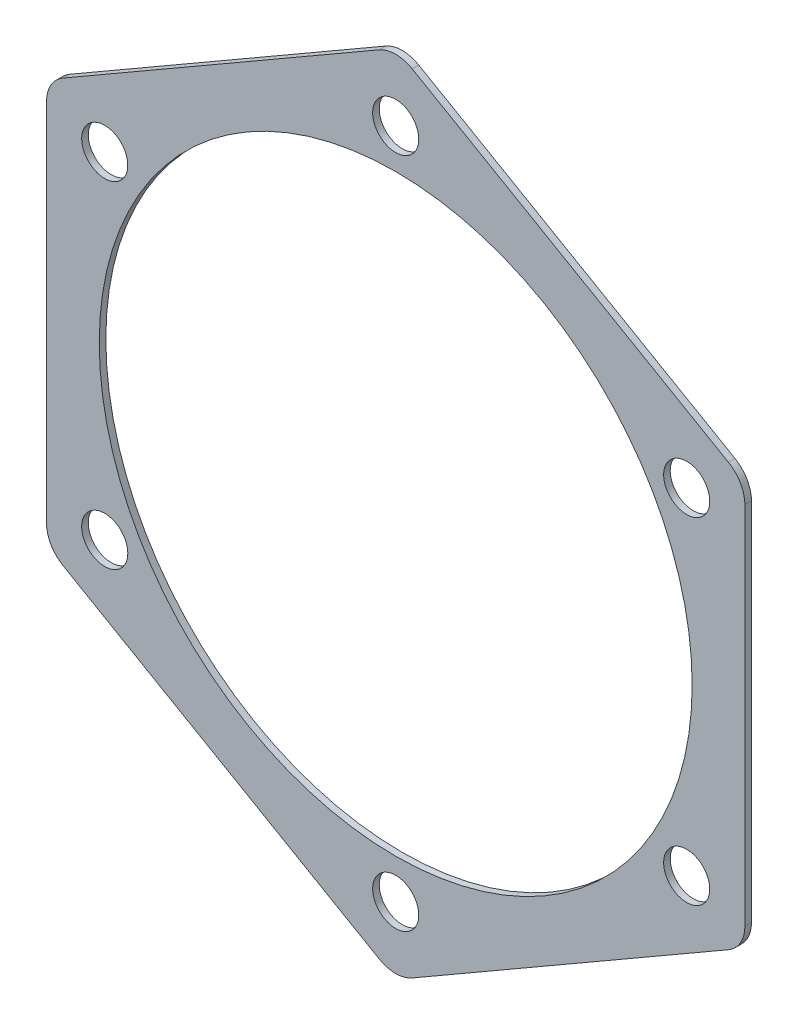
from build123d import *

# Parameters (mm, degrees)
BODY_DEPTH        = 0.5
SKETCH2_R         = 45
CENTER_HOLE_DEPTH = 0.5
SKETCH3_R         = 3.5
OUTER_HOLES_DEPTH = 0.5
CIRPATTERN1_COUNT = 6
R5_FILLETS_R      = 5


with BuildPart() as part:
    # Sketch1 → Body (new body, symmetric)
    with BuildSketch(Plane.XY):
        Polygon((0, 61.199128534), (-53, 30.599564267), (-53, -30.599564267), (0, -61.199128534), (53, -30.599564267), (53, 30.599564267), align=None)
    extrude(amount=BODY_DEPTH, both=True)

    # Sketch2 → Center Hole (cut, symmetric)
    with BuildSketch(Plane.XY):
        Circle(SKETCH2_R)
    extrude(amount=CENTER_HOLE_DEPTH, both=True, mode=Mode.SUBTRACT)

    # Sketch3 → Outer Holes (cut, symmetric)
    with BuildSketch(Plane.XY):
        with Locations((0, 51)):
            Circle(SKETCH3_R)
    outer_holes = extrude(amount=OUTER_HOLES_DEPTH, both=True, mode=Mode.SUBTRACT)

    # CirPattern1: Outer Holes ×6 about axis
    cirpattern1_axis = Axis((0, 0, 0), (0, 0, 1))
    for i in range(1, CIRPATTERN1_COUNT):
        add(outer_holes.rotate(cirpattern1_axis, i * 360 / CIRPATTERN1_COUNT), mode=Mode.SUBTRACT)

    # R5 Fillets
    r5_fillets_edges = [part.edges().sort_by_distance(p)[0] for p in [
        (53, 30.599564267, 0),
        (53, -30.599564267, 0),
        (0, -61.199128534, 0),
        (-53, -30.599564267, 0),
        (-53, 30.599564267, 0),
        (0, 61.199128534, 0),
    ]]
    fillet(r5_fillets_edges, radius=R5_FILLETS_R)


solid = part.part
